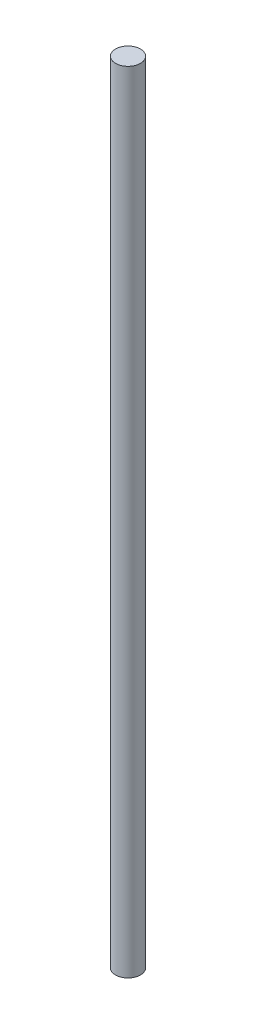
from build123d import *

# Parameters (mm, degrees)
SKETCH1_R           = 4.6609
BOSS_EXTRUDE1_DEPTH = 295.275


with BuildPart() as part:
    # Sketch1 → Boss-Extrude1 (new body)
    with BuildSketch(Plane(origin=(0, 0, 0), x_dir=(1, 0, 0), z_dir=(0, 1, 0))):
        Circle(SKETCH1_R)
    extrude(amount=BOSS_EXTRUDE1_DEPTH)


solid = part.part
